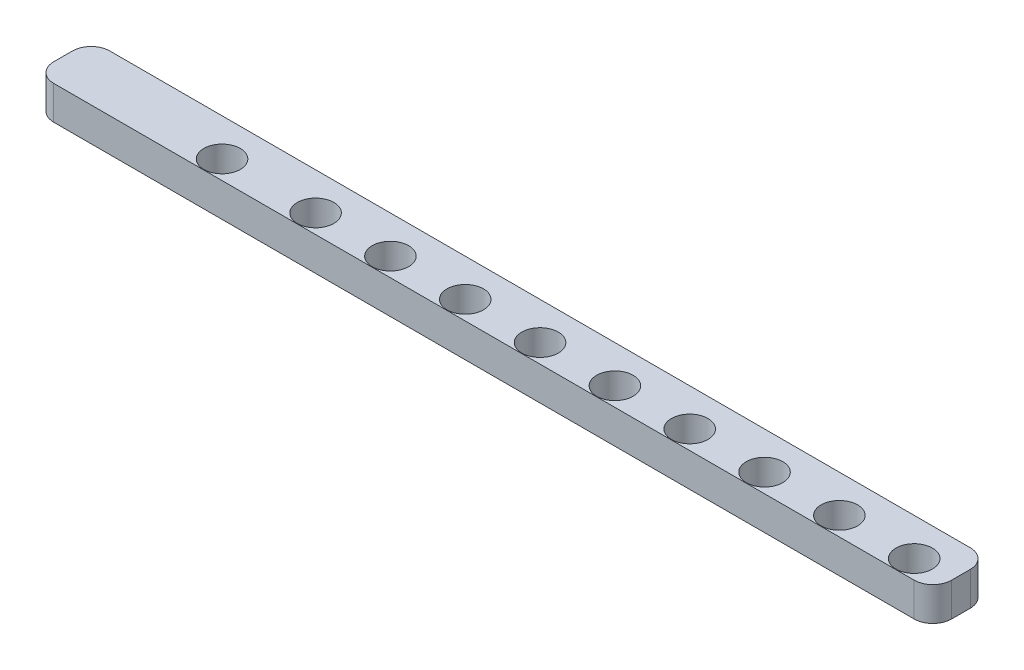
from build123d import *

# Parameters (mm, degrees)
BOSS_EXTRUDE1_DEPTH = 3.6
SKETCH2_R           = 1.95
CUT_EXTRUDE1_DEPTH  = 3.6


with BuildPart() as part:
    # Sketch1 → Boss-Extrude1 (new body)
    with BuildSketch(Plane(origin=(0, 0, 0), x_dir=(1, 0, 0), z_dir=(0, 1, 0))):
        with BuildLine():
            Line((2, 0), (94, 0))
            ThreePointArc((94, 0), (95.414213562, -0.585786438), (96, -2))
            Line((96, -2), (96, -4))
            ThreePointArc((96, -4), (95.414213562, -5.414213562), (94, -6))
            Line((94, -6), (2, -6))
            ThreePointArc((2, -6), (0.585786438, -5.414213562), (0, -4))
            Line((0, -4), (0, -2))
            ThreePointArc((0, -2), (0.585786438, -0.585786438), (2, 0))
        make_face()
    extrude(amount=BOSS_EXTRUDE1_DEPTH)

    # Sketch2 → Cut-Extrude1 (cut)
    with BuildSketch(Plane(origin=(0, 3.6, 0), x_dir=(1, 0, 0), z_dir=(0, 1, 0))):
        with Locations((92, -4)):
            Circle(SKETCH2_R)
        with Locations((84, -4)):
            Circle(SKETCH2_R)
        with Locations((18, -4)):
            Circle(SKETCH2_R)
        with Locations((28, -4)):
            Circle(SKETCH2_R)
        with Locations((36, -4)):
            Circle(SKETCH2_R)
        with Locations((44, -4)):
            Circle(SKETCH2_R)
        with Locations((52, -4)):
            Circle(SKETCH2_R)
        with Locations((60, -4)):
            Circle(SKETCH2_R)
        with Locations((68, -4)):
            Circle(SKETCH2_R)
        with Locations((76, -4)):
            Circle(SKETCH2_R)
    extrude(amount=-CUT_EXTRUDE1_DEPTH, mode=Mode.SUBTRACT)


solid = part.part
